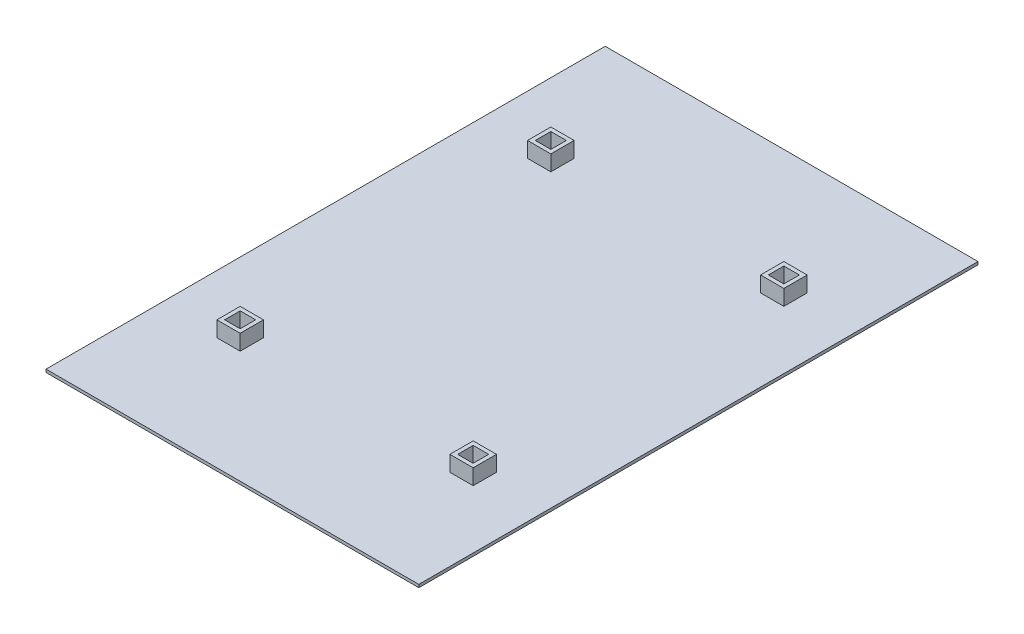
from build123d import *

# Parameters (mm, degrees)
SKETCH1_W           = 609.6
SKETCH1_H           = 914.4
BOSS_EXTRUDE1_DEPTH = 4.7625
SKETCH4_W           = 38.1
SKETCH4_H           = 38.1
SKETCH4_W_2         = 25.4
SKETCH4_H_2         = 25.4
BOSS_EXTRUDE2_DEPTH = 25.4


with BuildPart() as part:
    # Sketch1 → Boss-Extrude1 (new body)
    with BuildSketch(Plane(origin=(0, 0, 0), x_dir=(1, 0, 0), z_dir=(0, 1, 0))):
        with Locations((304.8, 457.2)):
            Rectangle(SKETCH1_W, SKETCH1_H)
    extrude(amount=BOSS_EXTRUDE1_DEPTH)

    # Sketch4 → Boss-Extrude2 (add)
    with BuildSketch(Plane(origin=(0, 4.7625, 0), x_dir=(1, 0, 0), z_dir=(0, 1, 0))):
        with Locations((114.3, 711.2)):
            Rectangle(SKETCH4_W, SKETCH4_H)
        with Locations((114.3, 711.2)):
            Rectangle(SKETCH4_W_2, SKETCH4_H_2, mode=Mode.SUBTRACT)
        with Locations((495.3, 711.2)):
            Rectangle(SKETCH4_W, SKETCH4_H)
        with Locations((495.3, 711.2)):
            Rectangle(SKETCH4_W_2, SKETCH4_H_2, mode=Mode.SUBTRACT)
        with Locations((495.3, 203.2)):
            Rectangle(SKETCH4_W, SKETCH4_H)
        with Locations((495.3, 203.2)):
            Rectangle(SKETCH4_W_2, SKETCH4_H_2, mode=Mode.SUBTRACT)
        with Locations((114.3, 203.2)):
            Rectangle(SKETCH4_W, SKETCH4_H)
        with Locations((114.3, 203.2)):
            Rectangle(SKETCH4_W_2, SKETCH4_H_2, mode=Mode.SUBTRACT)
    extrude(amount=BOSS_EXTRUDE2_DEPTH)


solid = part.part
